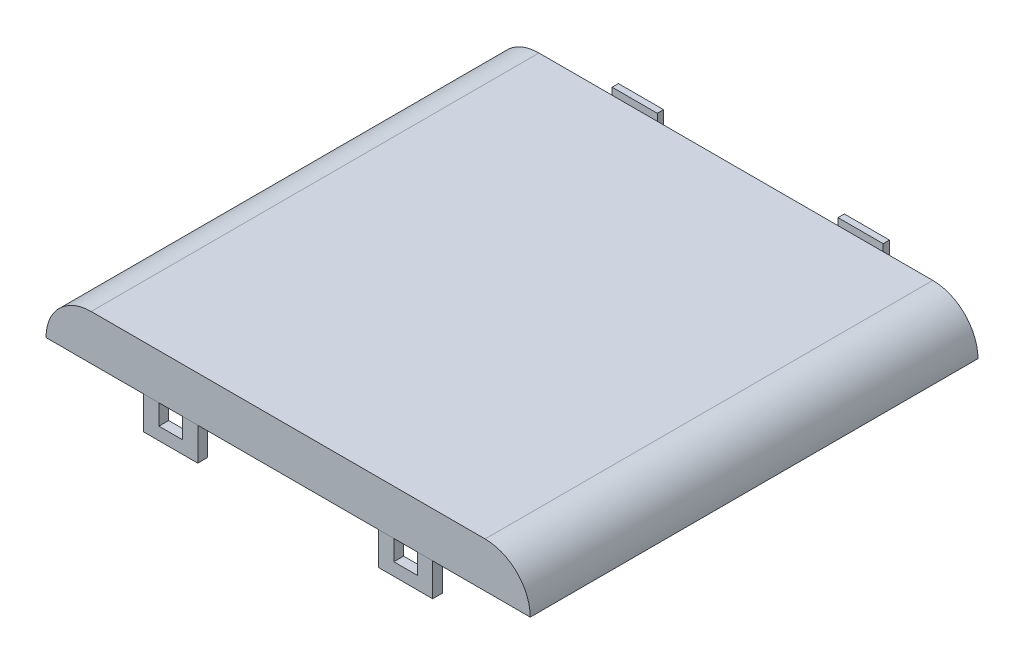
from build123d import *

# Parameters (mm, degrees)
SKETCH1_W                = 68.072
SKETCH1_H                = 62.9412
BOSS_EXTRUDE1_DEPTH      = 18.9103
FILLET1_R                = 6.35
SKETCH36_W               = 62.9412
SKETCH36_H               = 12.5603
CUT_EXTRUDE13_DEPTH      = 1
CUT_EXTRUDE13_DEPTH_BACK = 69.072
BOSS_EXTRUDE2_DEPTH      = 1.3716
BOSS_EXTRUDE2_2_DEPTH    = 1.3716
SHELL1_T                 = -1.3716
CUT_EXTRUDE14_DEPTH      = 1.3716
SKETCH41_W               = 6.35
SKETCH41_H               = 3.6449
BOSS_EXTRUDE4_DEPTH      = 2.54
SKETCH42_W               = 38.1
SKETCH42_H               = 1.27
CUT_EXTRUDE15_DEPTH      = 2.54
SKETCH43_W               = 1.654238959
SKETCH43_H               = 1.41141074
CUT_EXTRUDE16_DEPTH      = 54.086


with BuildPart() as part:
    # Sketch1 → Boss-Extrude1 (new body)
    with BuildSketch(Plane(origin=(0, 0, 0), x_dir=(1, 0, 0), z_dir=(0, 1, 0))):
        Rectangle(SKETCH1_W, SKETCH1_H)
    extrude(amount=BOSS_EXTRUDE1_DEPTH)

    # Fillet1
    fillet1_edges = [part.edges().sort_by_distance(p)[0] for p in [
        (34.036, 18.9103, 0),
        (-34.036, 18.9103, 0),
        (34.036, 0, 0),
        (-34.036, 0, 0),
    ]]
    fillet(fillet1_edges, radius=FILLET1_R)

    # Sketch36 → Cut-Extrude13 (cut, two sides)
    with BuildSketch(Plane(origin=(34.036, 0, 0), x_dir=(0, 0, -1), z_dir=(1, 0, 0))) as cut_extrude13_sk:
        with Locations((0, 6.28015)):
            Rectangle(SKETCH36_W, SKETCH36_H)
    extrude(amount=CUT_EXTRUDE13_DEPTH, mode=Mode.SUBTRACT)
    extrude(cut_extrude13_sk.sketch, amount=-CUT_EXTRUDE13_DEPTH_BACK, mode=Mode.SUBTRACT)

    # Shell1
    shell1_openings = [part.faces().sort_by_distance(p)[0] for p in [
        (0, 12.5603, 0),
    ]]
    offset(amount=SHELL1_T, openings=shell1_openings, kind=Kind.INTERSECTION)

    # Sketch40 → Cut-Extrude14 (cut)
    with BuildSketch(Plane(origin=(0, 0, -31.4706), x_dir=(-1, 0, 0), z_dir=(0, 0, -1))):
        with BuildLine():
            Line((27.686, 15.8623), (-27.686, 15.8623))
            ThreePointArc((-27.686, 15.8623), (-30.020866591, 14.895166591), (-30.988, 12.5603))
            Line((-30.988, 12.5603), (30.988, 12.5603))
            ThreePointArc((30.988, 12.5603), (30.020866591, 14.895166591), (27.686, 15.8623))
        make_face()
    extrude(amount=-CUT_EXTRUDE14_DEPTH, mode=Mode.SUBTRACT)

    # Sketch41 → Boss-Extrude4 (add)
    with BuildSketch(Plane(origin=(0, 0, -31.4706), x_dir=(-1, 0, 0), z_dir=(0, 0, -1))):
        with Locations((-15.875, 17.68475)):
            Rectangle(SKETCH41_W, SKETCH41_H)
        with Locations((15.875, 17.68475)):
            Rectangle(SKETCH41_W, SKETCH41_H)
    extrude(amount=BOSS_EXTRUDE4_DEPTH)

    # Sketch42 → Cut-Extrude15 (cut)
    with BuildSketch(Plane(origin=(0, 0, -34.0106), x_dir=(-1, 0, 0), z_dir=(0, 0, -1))):
        with Locations((0, 18.8722)):
            Rectangle(SKETCH42_W, SKETCH42_H)
    extrude(amount=-CUT_EXTRUDE15_DEPTH, mode=Mode.SUBTRACT)

    # Sketch43 → Cut-Extrude16 (cut, through all)
    with BuildSketch(Plane.ZY.offset(19.05)):
        with Locations((-32.29771948, 17.53149463)):
            Rectangle(SKETCH43_W, SKETCH43_H)
    extrude(amount=-CUT_EXTRUDE16_DEPTH, mode=Mode.SUBTRACT)


with BuildPart() as body_2:
    # Sketch37 → Boss-Extrude2 (new body)
    with BuildSketch(Plane.XY.offset(31.4706)):
        Polygon((-18.161, 12.5603), (-20.32, 12.5603), (-20.32, 7.9375), (-12.7, 7.9375), (-12.7, 12.5603), (-14.859, 12.5603), (-14.859, 9.7155), (-18.161, 9.7155), align=None)
    extrude(amount=-BOSS_EXTRUDE2_DEPTH)


with BuildPart() as body_3:
    # Sketch37 → Boss-Extrude2 2 (new body)
    with BuildSketch(Plane.XY.offset(31.4706)):
        Polygon((14.859, 12.5603), (12.7, 12.5603), (12.7, 7.9375), (20.32, 7.9375), (20.32, 12.5603), (18.161, 12.5603), (18.161, 9.7155), (14.859, 9.7155), align=None)
    extrude(amount=-BOSS_EXTRUDE2_2_DEPTH)


solid = Compound([part.part, body_2.part, body_3.part])
